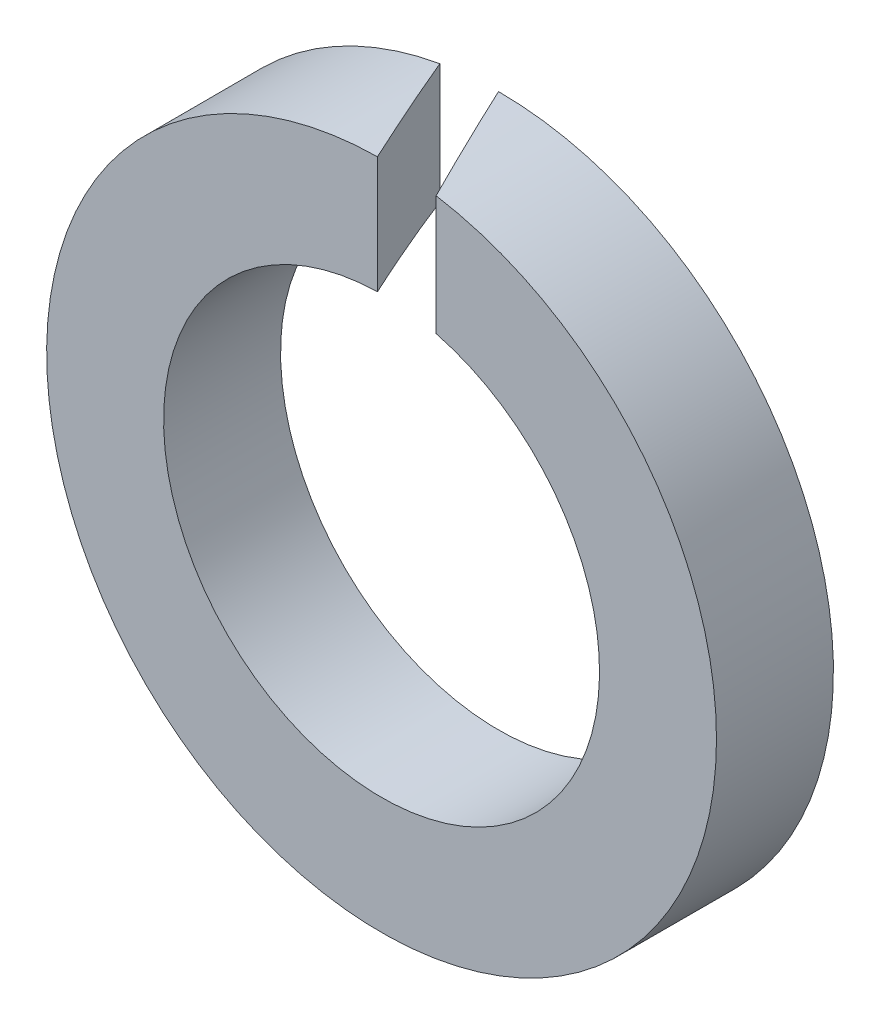
from build123d import *

# Parameters (mm, degrees)
SKETCH_1_R          = 3.15
SKETCH_1_R_2        = 2.05
EXTRUDE_1_DEPTH     = 1.1
CUT_EXTRUDE_1_DEPTH = 4.15


with BuildPart() as part:
    # 草图1 → 凸台-拉伸1 (new body)
    with BuildSketch(Plane.XY):
        Circle(SKETCH_1_R)
        Circle(SKETCH_1_R_2, mode=Mode.SUBTRACT)
    extrude(amount=EXTRUDE_1_DEPTH)

    # 草图2 → 切除-拉伸1 (cut, through all)
    with BuildSketch(Plane(origin=(0, 0, 0), x_dir=(1, 0, 0), z_dir=(0, 1, 0))):
        Polygon((0, 0), (0.512938424, -1.1), (-0.038750536, -1.1), (-0.551688959, 0), align=None)
    extrude(amount=CUT_EXTRUDE_1_DEPTH, mode=Mode.SUBTRACT)


solid = part.part
